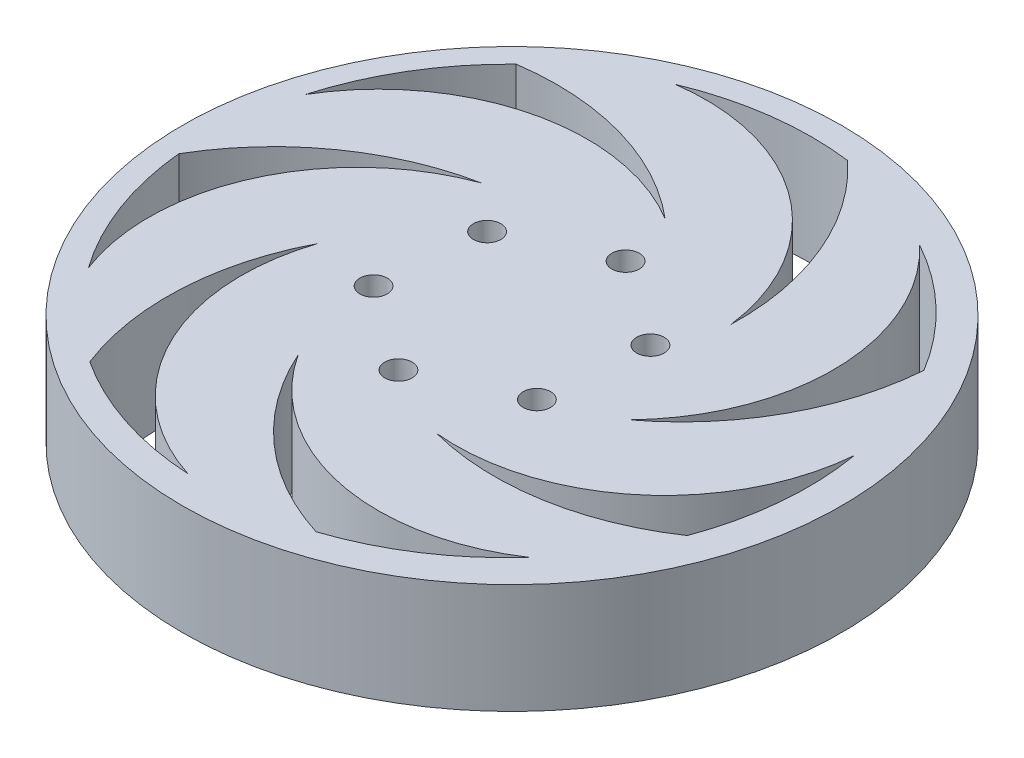
from build123d import *

# Parameters (mm, degrees)
SKETCH1_R           = 30
BOSS_EXTRUDE1_DEPTH = 10
CUT_EXTRUDE1_REACH  = 12
SKETCH2_R           = 1.25
CUT_EXTRUDE4_DEPTH  = 10
CIRPATTERN2_COUNT   = 7


with BuildPart() as part:
    # Sketch1 → Boss-Extrude1 (new body)
    with BuildSketch(Plane(origin=(0, 0, 0), x_dir=(1, 0, 0), z_dir=(0, 1, 0))):
        Circle(SKETCH1_R)
    extrude(amount=BOSS_EXTRUDE1_DEPTH)

    # Sketch2 → Cut-Extrude1 (cut, up to next)
    with BuildSketch(Plane(origin=(0, 10, 0), x_dir=(1, 0, 0), z_dir=(0, 1, 0)), mode=Mode.PRIVATE) as cut_extrude1_sk1:
        with Locations((-7.753929223, 5.488768678)):
            Circle(SKETCH2_R)
    cut_extrude1_tool1 = extrude(cut_extrude1_sk1.sketch, amount=-CUT_EXTRUDE1_REACH, mode=Mode.PRIVATE) & part.part
    add(cut_extrude1_tool1.solids().sort_by_distance((-7.753929, 10, -5.488769))[0], mode=Mode.SUBTRACT)
    # Sketch2 → Cut-Extrude1 (cut, up to next)
    with BuildSketch(Plane(origin=(0, 10, 0), x_dir=(1, 0, 0), z_dir=(0, 1, 0)), mode=Mode.PRIVATE) as cut_extrude1_sk2:
        with Locations((0.876448499, 9.459484025)):
            Circle(SKETCH2_R)
    cut_extrude1_tool2 = extrude(cut_extrude1_sk2.sketch, amount=-CUT_EXTRUDE1_REACH, mode=Mode.PRIVATE) & part.part
    add(cut_extrude1_tool2.solids().sort_by_distance((0.876448, 10, -9.459484))[0], mode=Mode.SUBTRACT)
    # Sketch2 → Cut-Extrude1 (cut, up to next)
    with BuildSketch(Plane(origin=(0, 10, 0), x_dir=(1, 0, 0), z_dir=(0, 1, 0)), mode=Mode.PRIVATE) as cut_extrude1_sk3:
        with Locations((8.630377722, 3.970715347)):
            Circle(SKETCH2_R)
    cut_extrude1_tool3 = extrude(cut_extrude1_sk3.sketch, amount=-CUT_EXTRUDE1_REACH, mode=Mode.PRIVATE) & part.part
    add(cut_extrude1_tool3.solids().sort_by_distance((8.630378, 10, -3.970715))[0], mode=Mode.SUBTRACT)
    # Sketch2 → Cut-Extrude1 (cut, up to next)
    with BuildSketch(Plane(origin=(0, 10, 0), x_dir=(1, 0, 0), z_dir=(0, 1, 0)), mode=Mode.PRIVATE) as cut_extrude1_sk4:
        with Locations((7.753929223, -5.488768678)):
            Circle(SKETCH2_R)
    cut_extrude1_tool4 = extrude(cut_extrude1_sk4.sketch, amount=-CUT_EXTRUDE1_REACH, mode=Mode.PRIVATE) & part.part
    add(cut_extrude1_tool4.solids().sort_by_distance((7.753929, 10, 5.488769))[0], mode=Mode.SUBTRACT)
    # Sketch2 → Cut-Extrude1 (cut, up to next)
    with BuildSketch(Plane(origin=(0, 10, 0), x_dir=(1, 0, 0), z_dir=(0, 1, 0)), mode=Mode.PRIVATE) as cut_extrude1_sk5:
        with Locations((-0.876448499, -9.459484025)):
            Circle(SKETCH2_R)
    cut_extrude1_tool5 = extrude(cut_extrude1_sk5.sketch, amount=-CUT_EXTRUDE1_REACH, mode=Mode.PRIVATE) & part.part
    add(cut_extrude1_tool5.solids().sort_by_distance((-0.876448, 10, 9.459484))[0], mode=Mode.SUBTRACT)
    # Sketch2 → Cut-Extrude1 (cut, up to next)
    with BuildSketch(Plane(origin=(0, 10, 0), x_dir=(1, 0, 0), z_dir=(0, 1, 0)), mode=Mode.PRIVATE) as cut_extrude1_sk6:
        with Locations((-8.630377722, -3.970715347)):
            Circle(SKETCH2_R)
    cut_extrude1_tool6 = extrude(cut_extrude1_sk6.sketch, amount=-CUT_EXTRUDE1_REACH, mode=Mode.PRIVATE) & part.part
    add(cut_extrude1_tool6.solids().sort_by_distance((-8.630378, 10, 3.970715))[0], mode=Mode.SUBTRACT)

    # Sketch6 → Cut-Extrude4 (cut)
    with BuildSketch(Plane(origin=(0, 10, 0), x_dir=(1, 0, 0), z_dir=(0, 1, 0))):
        with BuildLine():
            ThreePointArc((24.68695866, -2.287317978), (16.889428305, -10.428386728), (5.851580512, -12.71845138))
            ThreePointArc((5.851580512, -12.71845138), (15.949007833, -13.13834176), (25.324062707, -9.36439256))
            ThreePointArc((25.324062707, -9.36439256), (26.329710343, -5.978825407), (26.884849336, -2.490958893))
            Line((26.884849336, -2.490958893), (24.68695866, -2.287317978))
        make_face()
        with BuildLine():
            ThreePointArc((26.613477911, 4.552229506), (25.97279828, 1.041593529), (24.68695866, -2.287317978))
            Line((24.68695866, -2.287317978), (26.884849336, -2.490958893))
            ThreePointArc((26.884849336, -2.490958893), (26.979981102, 1.039528618), (26.613477911, 4.552229506))
        make_face()
    cut_extrude4 = extrude(amount=-CUT_EXTRUDE4_DEPTH, mode=Mode.SUBTRACT)

    # CirPattern2: Cut-Extrude4 ×7 about axis
    cirpattern2_axis = Axis((-0.506628383, 0, -0.191712569), (0, 1, 0))
    for i in range(1, CIRPATTERN2_COUNT):
        add(cut_extrude4.rotate(cirpattern2_axis, i * 360 / CIRPATTERN2_COUNT), mode=Mode.SUBTRACT)


solid = part.part
